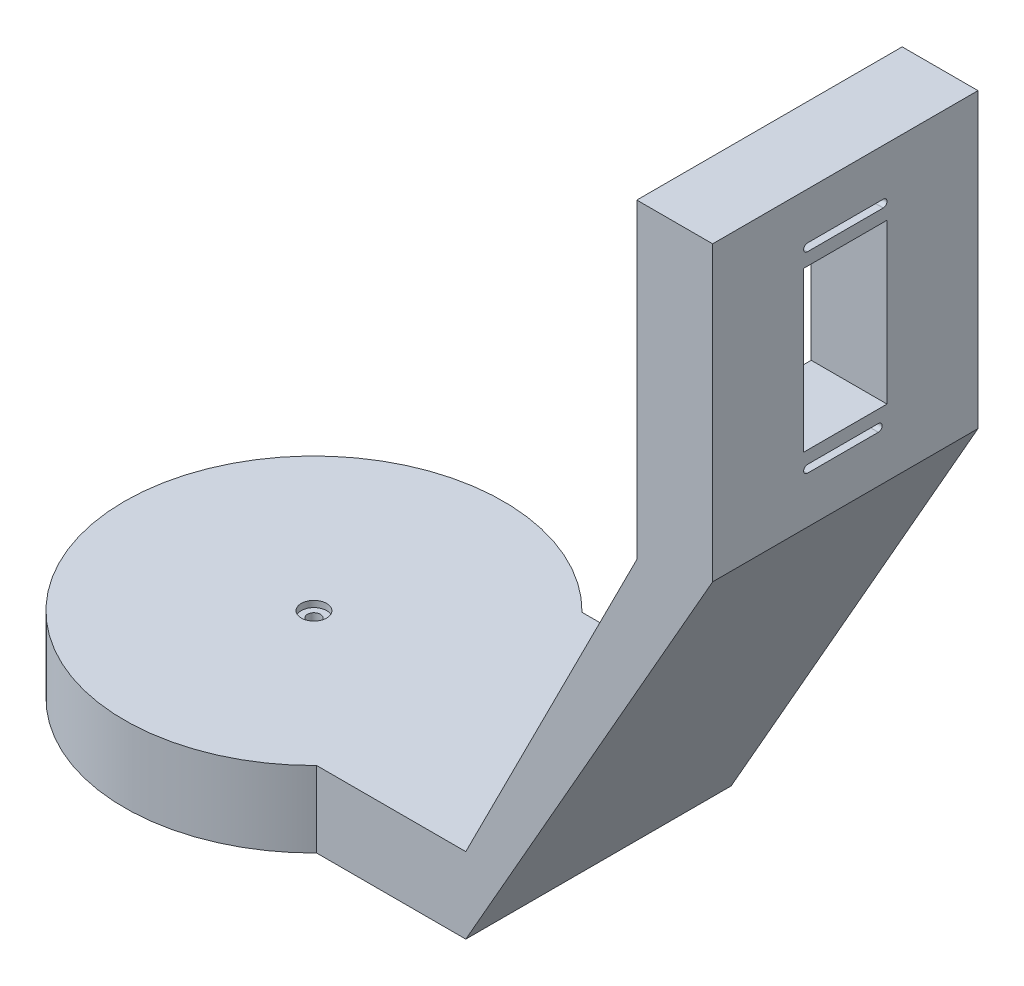
from build123d import *

# Parameters (mm, degrees)
EXTRUDE_1_DEPTH        = 20
EXTRUDE_2_DEPTH        = 70
F_1_4_BASE_D           = 3.4
F_1_4_BASE_CBORE_D     = 6.7
F_1_4_BASE_CBORE_DEPTH = 1.65
SKETCH_11_W            = 22
SKETCH_11_H            = 42
CUT_EXTRUDE_1_DEPTH    = 32
CUT_EXTRUDE_2_DEPTH    = 67
CUT_EXTRUDE_3_DEPTH    = 2
CUT_EXTRUDE_4_DEPTH    = 3.5


with BuildPart() as part:
    # 草图1 → 凸台-拉伸1 (new body)
    with BuildSketch(Plane(origin=(0, 0, 0), x_dir=(1, 0, 0), z_dir=(0, 1, 0))):
        with BuildLine():
            Line((75.055476805, 35), (35.707142143, 35))
            ThreePointArc((35.707142143, 35), (46.289075964, 18.902948088), (50, 0))
            ThreePointArc((50, 0), (46.289075964, -18.902948088), (35.707142143, -35))
            Line((35.707142143, -35), (75.055476805, -35))
            Line((75.055476805, -35), (75.055476805, 35))
        make_face()
        with BuildLine():
            Line((0.055476805, -35), (0.055476805, 35))
            Line((0.055476805, 35), (35.707142143, 35))
            ThreePointArc((35.707142143, 35), (-50, 0), (35.707142143, -35))
            Line((35.707142143, -35), (0.055476805, -35))
        make_face()
        with BuildLine():
            Line((35.707142143, 35), (0.055476805, 35))
            Line((0.055476805, 35), (0.055476805, -35))
            Line((0.055476805, -35), (35.707142143, -35))
            ThreePointArc((35.707142143, -35), (46.289075964, -18.902948088), (50, 0))
            ThreePointArc((50, 0), (46.289075964, 18.902948088), (35.707142143, 35))
        make_face()
    extrude(amount=EXTRUDE_1_DEPTH)

    # 草图2 → 凸台-拉伸2 (add)
    with BuildSketch(Plane.XY.offset(35)):
        Polygon((75.055476805, 0), (140.174133177, 114.192122372), (140.174133177, 191.411564081), (120.174133177, 191.411564081), (120.174133177, 109.286292207), (75.055476805, 20), align=None)
    extrude(amount=-EXTRUDE_2_DEPTH)

    # 1/4 六角头螺钉的柱形沉头孔base (through all)
    with Locations(Plane(origin=(0, 20, 0), x_dir=(1, 0, 0), z_dir=(0, 1, 0))):
        with Locations((0, 0)):
            CounterBoreHole(F_1_4_BASE_D / 2, F_1_4_BASE_CBORE_D / 2, F_1_4_BASE_CBORE_DEPTH)

    # 草图11 → 切除-拉伸1 (cut)
    with BuildSketch(Plane(origin=(140.174133177, 0, 0), x_dir=(0, 0, -1), z_dir=(1, 0, 0))):
        with Locations((0, 152.801564081)):
            Rectangle(SKETCH_11_W, SKETCH_11_H)
    extrude(amount=-CUT_EXTRUDE_1_DEPTH, mode=Mode.SUBTRACT)

    # 草图14 → 切除-拉伸2 (cut)
    with BuildSketch(Plane(origin=(140.174133177, 0, 0), x_dir=(0, 0, -1), z_dir=(1, 0, 0))):
        with BuildLine():
            Line((-10, 179.101564081), (10, 179.101564081))
            ThreePointArc((10, 179.101564081), (11, 178.101564081), (10, 177.101564081))
            Line((10, 177.101564081), (-10, 177.101564081))
            ThreePointArc((-10, 177.101564081), (-11, 178.101564081), (-10, 179.101564081))
        make_face()
        with BuildLine():
            Line((-10, 128.501564081), (8.706275956, 128.501564081))
            ThreePointArc((8.706275956, 128.501564081), (9.706275956, 127.501564081), (8.706275956, 126.501564081))
            Line((8.706275956, 126.501564081), (-10, 126.501564081))
            ThreePointArc((-10, 126.501564081), (-11, 127.501564081), (-10, 128.501564081))
        make_face()
    extrude(amount=-CUT_EXTRUDE_2_DEPTH, mode=Mode.SUBTRACT)

    # 草图19 → 切除-拉伸3 (cut)
    with BuildSketch(Plane.XZ):
        with BuildLine():
            Line((-29.938978194, 2.983548036), (0, 6))
            Line((0, 6), (29.925496738, 2.977040035))
            ThreePointArc((29.925496738, 2.977040035), (32.999946297, -0.039985046), (29.889613095, -3.020003134))
            Line((29.889613095, -3.020003134), (0, -6))
            Line((0, -6), (-30.07371717, -4.263466486))
            ThreePointArc((-30.07371717, -4.263466486), (-33.623512821, -0.572707651), (-29.938978194, 2.983548036))
        make_face()
    extrude(amount=-CUT_EXTRUDE_3_DEPTH, mode=Mode.SUBTRACT)

    # 草图20 → 切除-拉伸4 (cut)
    with BuildSketch(Plane.XZ):
        Polygon((0, 6), (-10.447108364, 4.947418969), (-10.447108364, -5.396757185), (0, -6), (10.446834114, -4.958449786), (10.446834114, 4.944700515), align=None)
    extrude(amount=-CUT_EXTRUDE_4_DEPTH, mode=Mode.SUBTRACT)


solid = part.part
